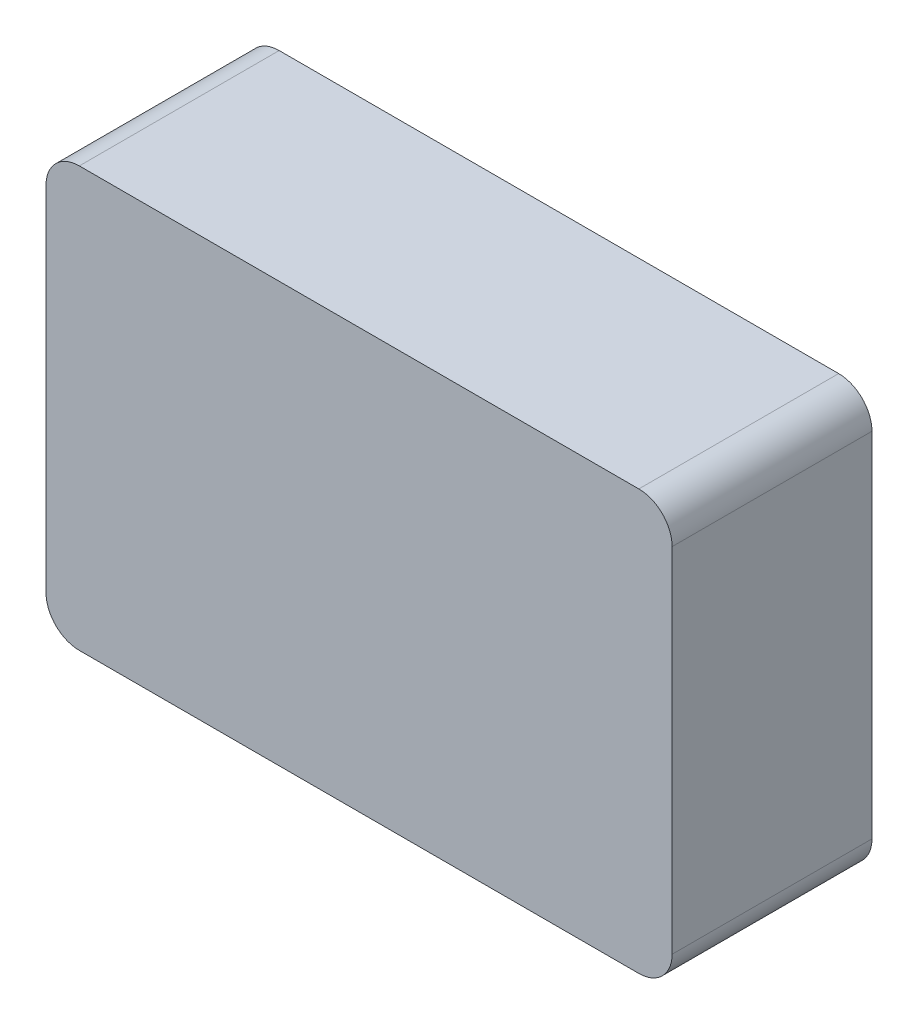
from build123d import *

# Parameters (mm, degrees)
BOSS_EXTRUDE1_DEPTH = 30
SKETCH2_R           = 2
CUT_EXTRUDE1_DEPTH  = 2
SKETCH3_W           = 20
SKETCH3_H           = 53
CUT_EXTRUDE2_DEPTH  = 5


with BuildPart() as part:
    # Sketch1 → Boss-Extrude1 (new body)
    with BuildSketch(Plane.XY):
        with BuildLine():
            Line((-42, 31.5), (42, 31.5))
            ThreePointArc((42, 31.5), (45.535533906, 30.035533906), (47, 26.5))
            Line((47, 26.5), (47, -26.5))
            ThreePointArc((47, -26.5), (45.535533906, -30.035533906), (42, -31.5))
            Line((42, -31.5), (-42, -31.5))
            ThreePointArc((-42, -31.5), (-45.535533906, -30.035533906), (-47, -26.5))
            Line((-47, -26.5), (-47, 26.5))
            ThreePointArc((-47, 26.5), (-45.535533906, 30.035533906), (-42, 31.5))
        make_face()
    extrude(amount=BOSS_EXTRUDE1_DEPTH)

    # Sketch2 → Cut-Extrude1 (cut)
    with BuildSketch(Plane.XZ.offset(31.5)):
        with Locations((15, 10)):
            Circle(SKETCH2_R)
        with BuildLine():
            Line((-35, 12), (-27, 12))
            ThreePointArc((-27, 12), (-25, 10), (-27, 8))
            Line((-27, 8), (-35, 8))
            ThreePointArc((-35, 8), (-37, 10), (-35, 12))
        make_face()
        with BuildLine():
            Line((-19, 12), (-11, 12))
            ThreePointArc((-11, 12), (-9, 10), (-11, 8))
            Line((-11, 8), (-19, 8))
            ThreePointArc((-19, 8), (-21, 10), (-19, 12))
        make_face()
        with BuildLine():
            Line((-3, 12), (5, 12))
            ThreePointArc((5, 12), (7, 10), (5, 8))
            Line((5, 8), (-3, 8))
            ThreePointArc((-3, 8), (-5, 10), (-3, 12))
        make_face()
    extrude(amount=-CUT_EXTRUDE1_DEPTH, mode=Mode.SUBTRACT)

    # Sketch3 → Cut-Extrude2 (cut)
    with BuildSketch(Plane.ZY.offset(47)):
        with Locations((15, 0)):
            Rectangle(SKETCH3_W, SKETCH3_H)
    extrude(amount=-CUT_EXTRUDE2_DEPTH, mode=Mode.SUBTRACT)


solid = part.part
